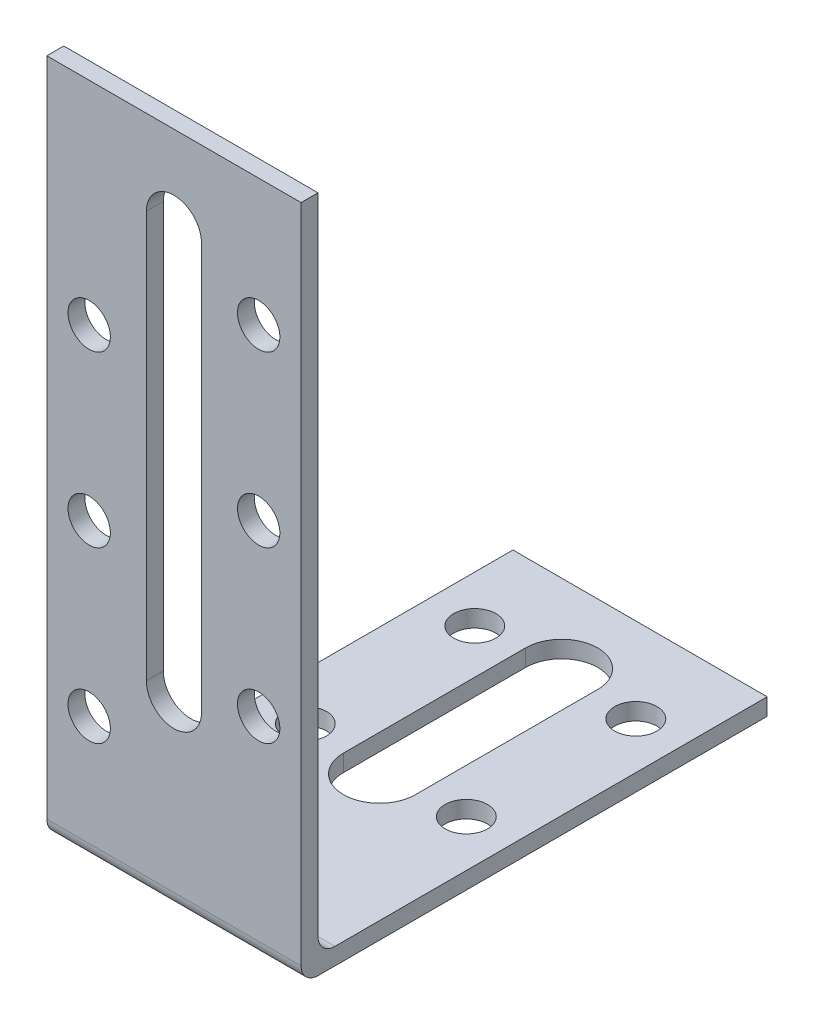
from build123d import *

# Parameters (mm, degrees)
BOSS_EXTRU_1_DEPTH      = 15
CONG_1_R                = 2
ENL_V_MAT_EXTRU_1_REACH = 4
ESQUISSE2_R             = 2.5
ENL_V_MAT_EXTRU_2_REACH = 4
ESQUISSE4_R             = 2.5


with BuildPart() as part:
    # Esquisse1 → Boss.-Extru.1 (new body, symmetric)
    with BuildSketch(Plane(origin=(0, 0, 0), x_dir=(0, 0, -1), z_dir=(1, 0, 0))):
        Polygon((0, 0), (0, 80), (2, 80), (2, 2), (55, 2), (55, 0), align=None)
    extrude(amount=BOSS_EXTRU_1_DEPTH, both=True)

    # Congé1
    cong_1_edges = [part.edges().sort_by_distance(p)[0] for p in [
        (0, 0, 0),
        (0, 2, -2),
    ]]
    fillet(cong_1_edges, radius=CONG_1_R)

    # Esquisse2 → Enlèv. mat.-Extru.1 (cut, up to next)
    with BuildSketch(Plane(origin=(0, 2, 0), x_dir=(1, 0, 0), z_dir=(0, 1, 0)), mode=Mode.PRIVATE) as enl_v_mat_extru_1_sk1:
        with BuildLine():
            Line((4.25, 24.25), (4.25, 45.75))
            ThreePointArc((4.25, 45.75), (0, 50), (-4.25, 45.75))
            Line((-4.25, 45.75), (-4.25, 24.25))
            ThreePointArc((-4.25, 24.25), (0, 20), (4.25, 24.25))
        make_face()
    enl_v_mat_extru_1_tool1 = extrude(enl_v_mat_extru_1_sk1.sketch, amount=-ENL_V_MAT_EXTRU_1_REACH, mode=Mode.PRIVATE) & part.part
    add(enl_v_mat_extru_1_tool1.solids().sort_by_distance((0, 2, -35))[0], mode=Mode.SUBTRACT)
    # Esquisse2 → Enlèv. mat.-Extru.1 (cut, up to next)
    with BuildSketch(Plane(origin=(0, 2, 0), x_dir=(1, 0, 0), z_dir=(0, 1, 0)), mode=Mode.PRIVATE) as enl_v_mat_extru_1_sk2:
        with Locations((-9.5, 25)):
            Circle(ESQUISSE2_R)
    enl_v_mat_extru_1_tool2 = extrude(enl_v_mat_extru_1_sk2.sketch, amount=-ENL_V_MAT_EXTRU_1_REACH, mode=Mode.PRIVATE) & part.part
    add(enl_v_mat_extru_1_tool2.solids().sort_by_distance((-9.5, 2, -25))[0], mode=Mode.SUBTRACT)
    # Esquisse2 → Enlèv. mat.-Extru.1 (cut, up to next)
    with BuildSketch(Plane(origin=(0, 2, 0), x_dir=(1, 0, 0), z_dir=(0, 1, 0)), mode=Mode.PRIVATE) as enl_v_mat_extru_1_sk3:
        with Locations((-9.5, 45)):
            Circle(ESQUISSE2_R)
    enl_v_mat_extru_1_tool3 = extrude(enl_v_mat_extru_1_sk3.sketch, amount=-ENL_V_MAT_EXTRU_1_REACH, mode=Mode.PRIVATE) & part.part
    add(enl_v_mat_extru_1_tool3.solids().sort_by_distance((-9.5, 2, -45))[0], mode=Mode.SUBTRACT)
    # Esquisse2 → Enlèv. mat.-Extru.1 (cut, up to next)
    with BuildSketch(Plane(origin=(0, 2, 0), x_dir=(1, 0, 0), z_dir=(0, 1, 0)), mode=Mode.PRIVATE) as enl_v_mat_extru_1_sk4:
        with Locations((9.5, 45)):
            Circle(ESQUISSE2_R)
    enl_v_mat_extru_1_tool4 = extrude(enl_v_mat_extru_1_sk4.sketch, amount=-ENL_V_MAT_EXTRU_1_REACH, mode=Mode.PRIVATE) & part.part
    add(enl_v_mat_extru_1_tool4.solids().sort_by_distance((9.5, 2, -45))[0], mode=Mode.SUBTRACT)
    # Esquisse2 → Enlèv. mat.-Extru.1 (cut, up to next)
    with BuildSketch(Plane(origin=(0, 2, 0), x_dir=(1, 0, 0), z_dir=(0, 1, 0)), mode=Mode.PRIVATE) as enl_v_mat_extru_1_sk5:
        with Locations((9.5, 25)):
            Circle(ESQUISSE2_R)
    enl_v_mat_extru_1_tool5 = extrude(enl_v_mat_extru_1_sk5.sketch, amount=-ENL_V_MAT_EXTRU_1_REACH, mode=Mode.PRIVATE) & part.part
    add(enl_v_mat_extru_1_tool5.solids().sort_by_distance((9.5, 2, -25))[0], mode=Mode.SUBTRACT)

    # Esquisse4 → Enlèv. mat.-Extru.2 (cut, up to next)
    with BuildSketch(Plane(origin=(0, 0, -2), x_dir=(-1, 0, 0), z_dir=(0, 0, -1)), mode=Mode.PRIVATE) as enl_v_mat_extru_2_sk1:
        with Locations((-10, 65)):
            Circle(ESQUISSE4_R)
    enl_v_mat_extru_2_tool1 = extrude(enl_v_mat_extru_2_sk1.sketch, amount=-ENL_V_MAT_EXTRU_2_REACH, mode=Mode.PRIVATE) & part.part
    add(enl_v_mat_extru_2_tool1.solids().sort_by_distance((10, 65, -2))[0], mode=Mode.SUBTRACT)
    # Esquisse4 → Enlèv. mat.-Extru.2 (cut, up to next)
    with BuildSketch(Plane(origin=(0, 0, -2), x_dir=(-1, 0, 0), z_dir=(0, 0, -1)), mode=Mode.PRIVATE) as enl_v_mat_extru_2_sk2:
        with Locations((-10, 45)):
            Circle(ESQUISSE4_R)
    enl_v_mat_extru_2_tool2 = extrude(enl_v_mat_extru_2_sk2.sketch, amount=-ENL_V_MAT_EXTRU_2_REACH, mode=Mode.PRIVATE) & part.part
    add(enl_v_mat_extru_2_tool2.solids().sort_by_distance((10, 45, -2))[0], mode=Mode.SUBTRACT)
    # Esquisse4 → Enlèv. mat.-Extru.2 (cut, up to next)
    with BuildSketch(Plane(origin=(0, 0, -2), x_dir=(-1, 0, 0), z_dir=(0, 0, -1)), mode=Mode.PRIVATE) as enl_v_mat_extru_2_sk3:
        with Locations((-10, 25)):
            Circle(ESQUISSE4_R)
    enl_v_mat_extru_2_tool3 = extrude(enl_v_mat_extru_2_sk3.sketch, amount=-ENL_V_MAT_EXTRU_2_REACH, mode=Mode.PRIVATE) & part.part
    add(enl_v_mat_extru_2_tool3.solids().sort_by_distance((10, 25, -2))[0], mode=Mode.SUBTRACT)
    # Esquisse4 → Enlèv. mat.-Extru.2 (cut, up to next)
    with BuildSketch(Plane(origin=(0, 0, -2), x_dir=(-1, 0, 0), z_dir=(0, 0, -1)), mode=Mode.PRIVATE) as enl_v_mat_extru_2_sk4:
        with Locations((10, 55)):
            Circle(ESQUISSE4_R)
    enl_v_mat_extru_2_tool4 = extrude(enl_v_mat_extru_2_sk4.sketch, amount=-ENL_V_MAT_EXTRU_2_REACH, mode=Mode.PRIVATE) & part.part
    add(enl_v_mat_extru_2_tool4.solids().sort_by_distance((-10, 55, -2))[0], mode=Mode.SUBTRACT)
    # Esquisse4 → Enlèv. mat.-Extru.2 (cut, up to next)
    with BuildSketch(Plane(origin=(0, 0, -2), x_dir=(-1, 0, 0), z_dir=(0, 0, -1)), mode=Mode.PRIVATE) as enl_v_mat_extru_2_sk5:
        with Locations((10, 35)):
            Circle(ESQUISSE4_R)
    enl_v_mat_extru_2_tool5 = extrude(enl_v_mat_extru_2_sk5.sketch, amount=-ENL_V_MAT_EXTRU_2_REACH, mode=Mode.PRIVATE) & part.part
    add(enl_v_mat_extru_2_tool5.solids().sort_by_distance((-10, 35, -2))[0], mode=Mode.SUBTRACT)
    # Esquisse4 → Enlèv. mat.-Extru.2 (cut, up to next)
    with BuildSketch(Plane(origin=(0, 0, -2), x_dir=(-1, 0, 0), z_dir=(0, 0, -1)), mode=Mode.PRIVATE) as enl_v_mat_extru_2_sk6:
        with Locations((10, 15)):
            Circle(ESQUISSE4_R)
    enl_v_mat_extru_2_tool6 = extrude(enl_v_mat_extru_2_sk6.sketch, amount=-ENL_V_MAT_EXTRU_2_REACH, mode=Mode.PRIVATE) & part.part
    add(enl_v_mat_extru_2_tool6.solids().sort_by_distance((-10, 15, -2))[0], mode=Mode.SUBTRACT)
    # Esquisse4 → Enlèv. mat.-Extru.2 (cut, up to next)
    with BuildSketch(Plane(origin=(0, 0, -2), x_dir=(-1, 0, 0), z_dir=(0, 0, -1)), mode=Mode.PRIVATE) as enl_v_mat_extru_2_sk7:
        with BuildLine():
            Line((3.25, 70), (3.25, 22))
            ThreePointArc((3.25, 22), (0, 18.75), (-3.25, 22))
            Line((-3.25, 22), (-3.25, 70))
            ThreePointArc((-3.25, 70), (0, 73.25), (3.25, 70))
        make_face()
    enl_v_mat_extru_2_tool7 = extrude(enl_v_mat_extru_2_sk7.sketch, amount=-ENL_V_MAT_EXTRU_2_REACH, mode=Mode.PRIVATE) & part.part
    add(enl_v_mat_extru_2_tool7.solids().sort_by_distance((0, 46, -2))[0], mode=Mode.SUBTRACT)


solid = part.part
